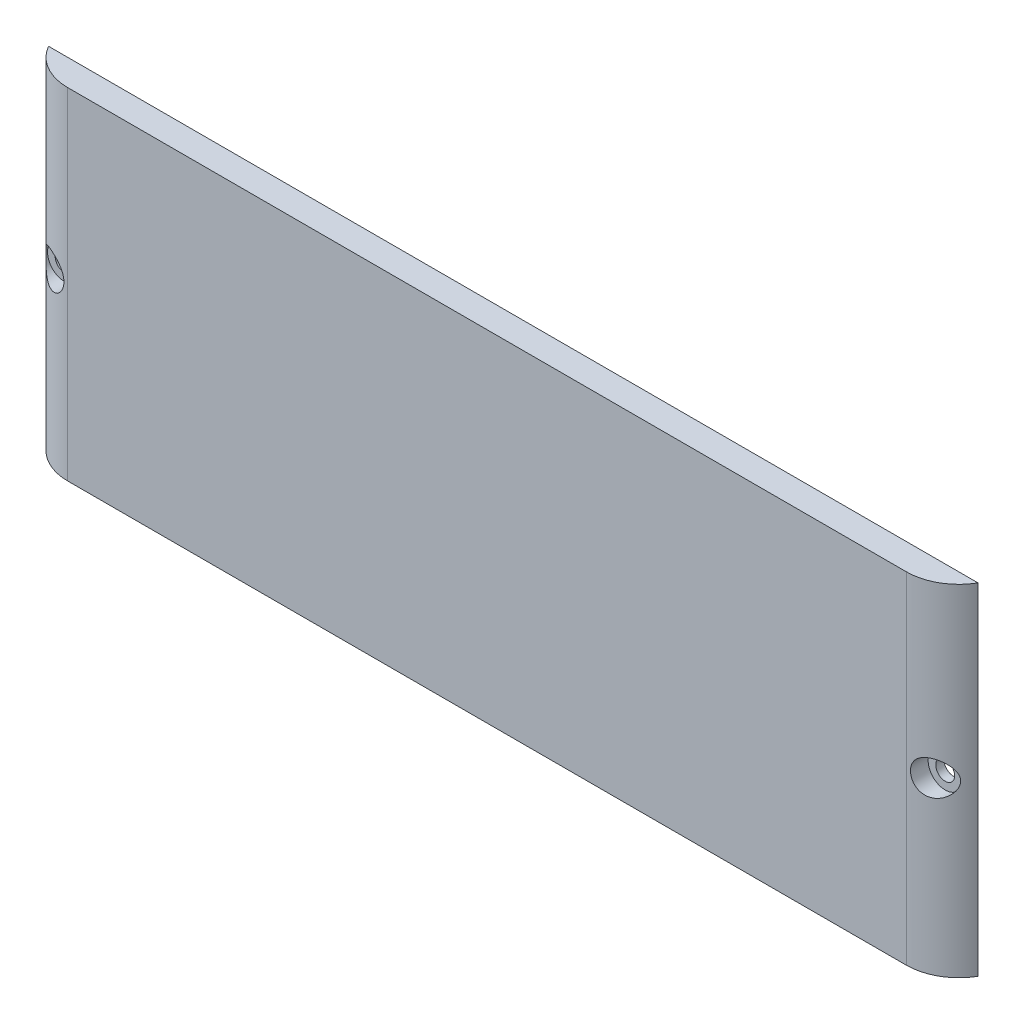
from build123d import *

# Parameters (mm, degrees)
SKIZZE1_W                                            = 180
SKIZZE1_H                                            = 65
AUFSATZ_LINEAR_AUSTRAGEN1_DEPTH                      = 5
STIRNSENKUNG_F_R_M3_ZYLINDERSCHRAUBE_MIT_D           = 3.6
STIRNSENKUNG_F_R_M3_ZYLINDERSCHRAUBE_MIT_DEPTH       = 9.1
STIRNSENKUNG_F_R_M3_ZYLINDERSCHRAUBE_MIT_CBORE_D     = 6.5
STIRNSENKUNG_F_R_M3_ZYLINDERSCHRAUBE_MIT_CBORE_DEPTH = 3.4
STIRNSENKUNG_F_R_M3_ZYLINDERSCHRAUBE_MIT_TIP         = 1.081549114
SCHNITT_LINEAR_AUSTRAGEN1_DEPTH                      = 66


with BuildPart() as part:
    # Skizze1 → Aufsatz-Linear austragen1 (new body)
    with BuildSketch(Plane.XY):
        Rectangle(SKIZZE1_W, SKIZZE1_H)
    extrude(amount=AUFSATZ_LINEAR_AUSTRAGEN1_DEPTH)

    # Stirnsenkung für M3 Zylinderschraube mit Innensechskant1
    with Locations(Plane.XY.offset(5)):
        with Locations((-84, 0), (84, 0)):
            CounterBoreHole(STIRNSENKUNG_F_R_M3_ZYLINDERSCHRAUBE_MIT_D / 2, STIRNSENKUNG_F_R_M3_ZYLINDERSCHRAUBE_MIT_CBORE_D / 2, STIRNSENKUNG_F_R_M3_ZYLINDERSCHRAUBE_MIT_CBORE_DEPTH, depth=STIRNSENKUNG_F_R_M3_ZYLINDERSCHRAUBE_MIT_DEPTH)
            with Locations((0, 0, -(STIRNSENKUNG_F_R_M3_ZYLINDERSCHRAUBE_MIT_DEPTH + STIRNSENKUNG_F_R_M3_ZYLINDERSCHRAUBE_MIT_TIP / 2))):  # 118° drill point
                Cone(0, STIRNSENKUNG_F_R_M3_ZYLINDERSCHRAUBE_MIT_D / 2, STIRNSENKUNG_F_R_M3_ZYLINDERSCHRAUBE_MIT_TIP, mode=Mode.SUBTRACT)

    # Skizze6 → Schnitt-Linear austragen1 (cut, through all)
    with BuildSketch(Plane(origin=(0, 32.5, 0), x_dir=(1, 0, 0), z_dir=(0, 1, 0))):
        with BuildLine():
            Line((-90, -5), (-90, 5))
            ThreePointArc((-90, 5), (-87.071067812, -2.071067812), (-80, -5))
            Line((-80, -5), (-90, -5))
        make_face()
        with BuildLine():
            Line((80, -5), (90, -5))
            Line((90, -5), (90, 5))
            ThreePointArc((90, 5), (87.071067812, -2.071067812), (80, -5))
        make_face()
    extrude(amount=-SCHNITT_LINEAR_AUSTRAGEN1_DEPTH, mode=Mode.SUBTRACT)


solid = part.part
